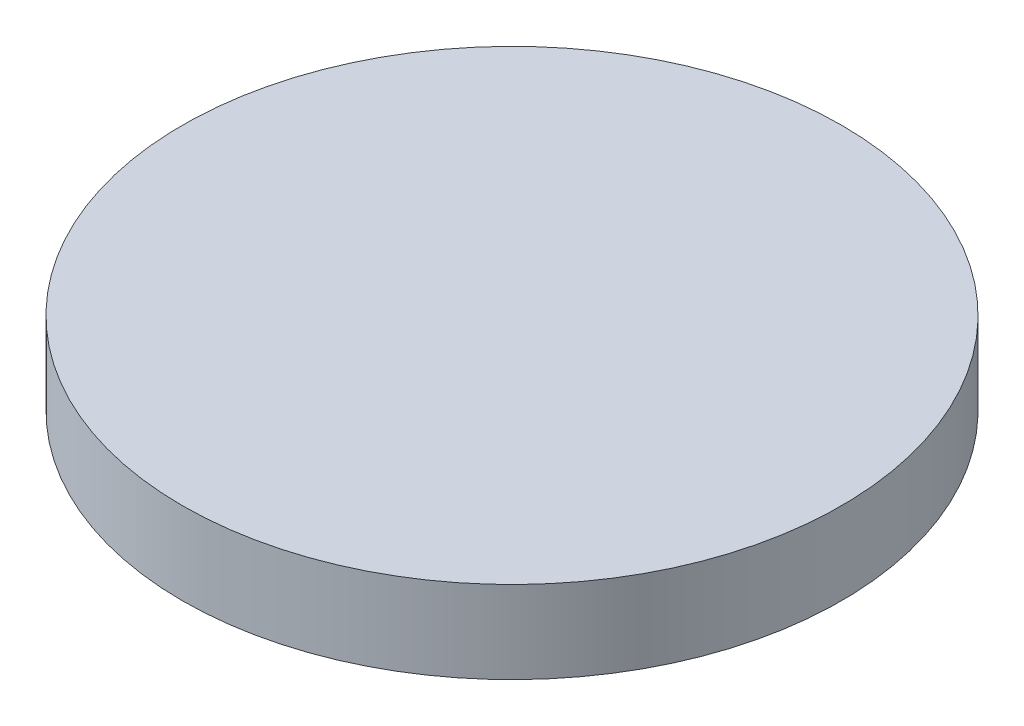
from build123d import *

# Parameters (mm, degrees)
SKETCH1_R           = 40
BOSS_EXTRUDE1_DEPTH = 10


with BuildPart() as part:
    # Sketch1 → Boss-Extrude1 (new body)
    with BuildSketch(Plane(origin=(0, 0, 0), x_dir=(1, 0, 0), z_dir=(0, 1, 0))):
        Circle(SKETCH1_R)
    extrude(amount=BOSS_EXTRUDE1_DEPTH)


solid = part.part
